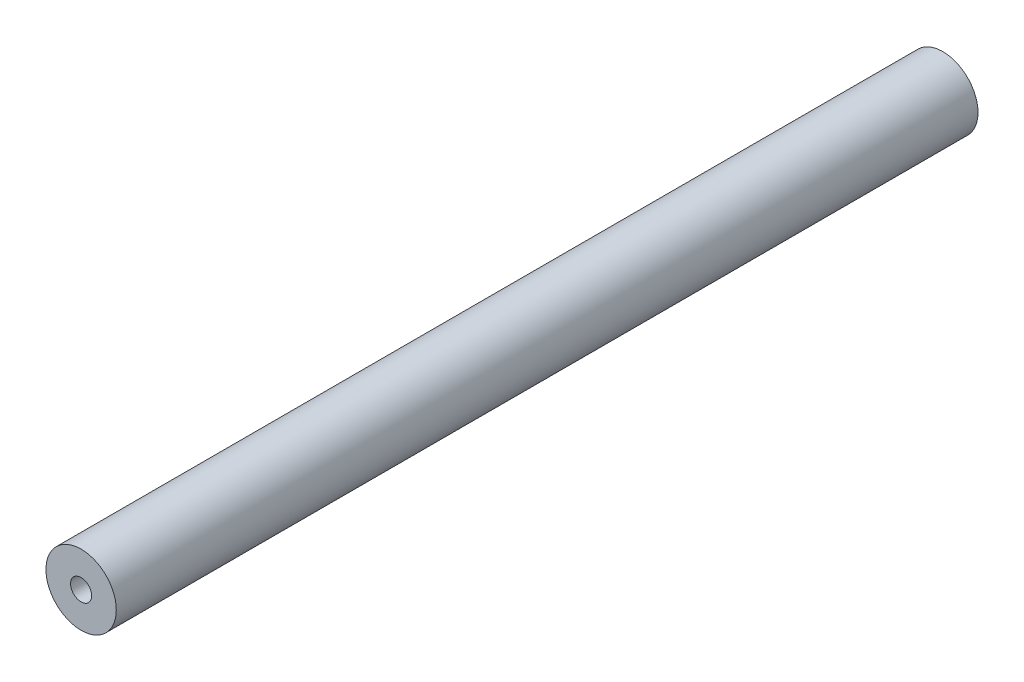
from build123d import *

# Parameters (mm, degrees)
SKETCH2_R           = 100
SKETCH2_R_2         = 30
BOSS_EXTRUDE1_DEPTH = 2450
SCALE1_SCALE        = 0.1


with BuildPart() as part:
    # Sketch2 → Boss-Extrude1 (new body)
    with BuildSketch(Plane.XY):
        Circle(SKETCH2_R)
        Circle(SKETCH2_R_2, mode=Mode.SUBTRACT)
    extrude(amount=BOSS_EXTRUDE1_DEPTH)


with BuildPart() as part_1:
    # Scale1: scaled about (0, 0, 1225)
    add(part.part.scale(SCALE1_SCALE).moved(Location((0, 0, 1102.5))))


solid = part_1.part
